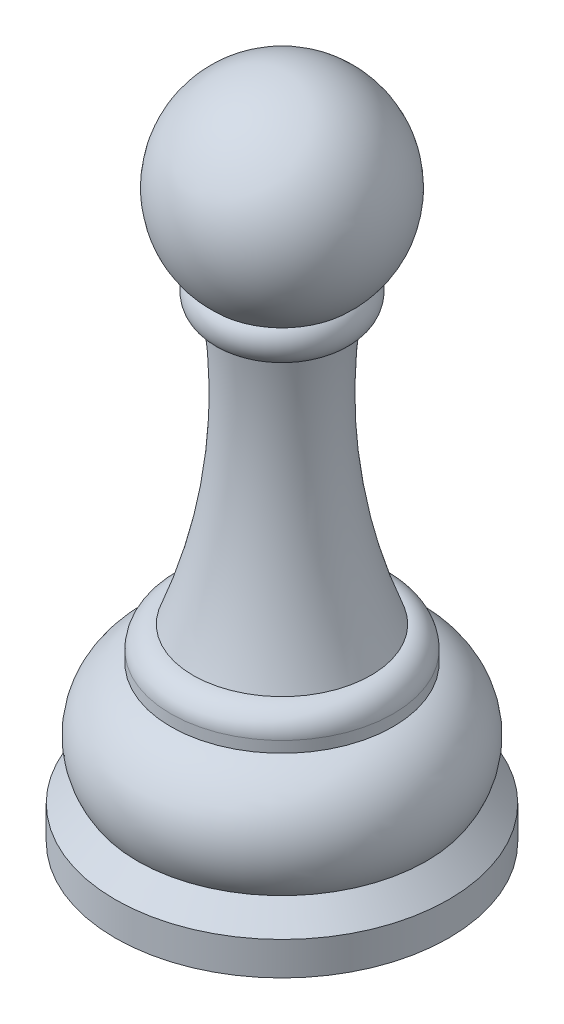
from build123d import *

# Parameters (mm, degrees)
SKETCH1_W = 10
SKETCH1_H = 1


with BuildPart() as part:
    # Sketch1 → Revolve1 (revolve)
    with BuildSketch(Plane.XY, mode=Mode.PRIVATE) as revolve1_sk:
        with BuildLine():
            Line((0, 44.29), (0, 60))
            ThreePointArc((0, 60), (-8.409682529, 54.211078624), (-6, 44.29))
            Line((-6, 44.29), (0, 44.29))
        make_face()
        with BuildLine():
            Line((0, 41.03), (0, 44.29))
            Line((0, 44.29), (-6, 44.29))
            ThreePointArc((-6, 44.29), (-6.412519214, 42.380086131), (-5, 41.03))
            Line((-5, 41.03), (0, 41.03))
        make_face()
        with BuildLine():
            Line((0, 16.97), (0, 41.03))
            Line((0, 41.03), (-5, 41.03))
            ThreePointArc((-5, 41.03), (-5.019495729, 28.81539847), (-8, 16.97))
            Line((-8, 16.97), (0, 16.97))
        make_face()
        with BuildLine():
            Line((0, 14.97), (0, 16.97))
            Line((0, 16.97), (-8, 16.97))
            ThreePointArc((-8, 16.97), (-9.414213562, 16.384213562), (-10, 14.97))
            Line((-10, 14.97), (0, 14.97))
        make_face()
        with Locations((-5, 14.47)):
            Rectangle(SKETCH1_W, SKETCH1_H)
        with BuildLine():
            Line((0, 5), (0, 13.97))
            Line((0, 13.97), (-10, 13.97))
            ThreePointArc((-10, 13.97), (-13.688325627, 10.216881481), (-13, 5))
            Line((-13, 5), (0, 5))
        make_face()
        Polygon((0, 0), (0, 5), (-13, 5), (-15, 3), (-15, 0), align=None)
    revolve(revolve1_sk.sketch.rotate(Axis((0, 69.118100181, 0), (0, -1, 0)), 270), axis=Axis((0, 69.118100181, 0), (0, -1, 0)))


solid = part.part
